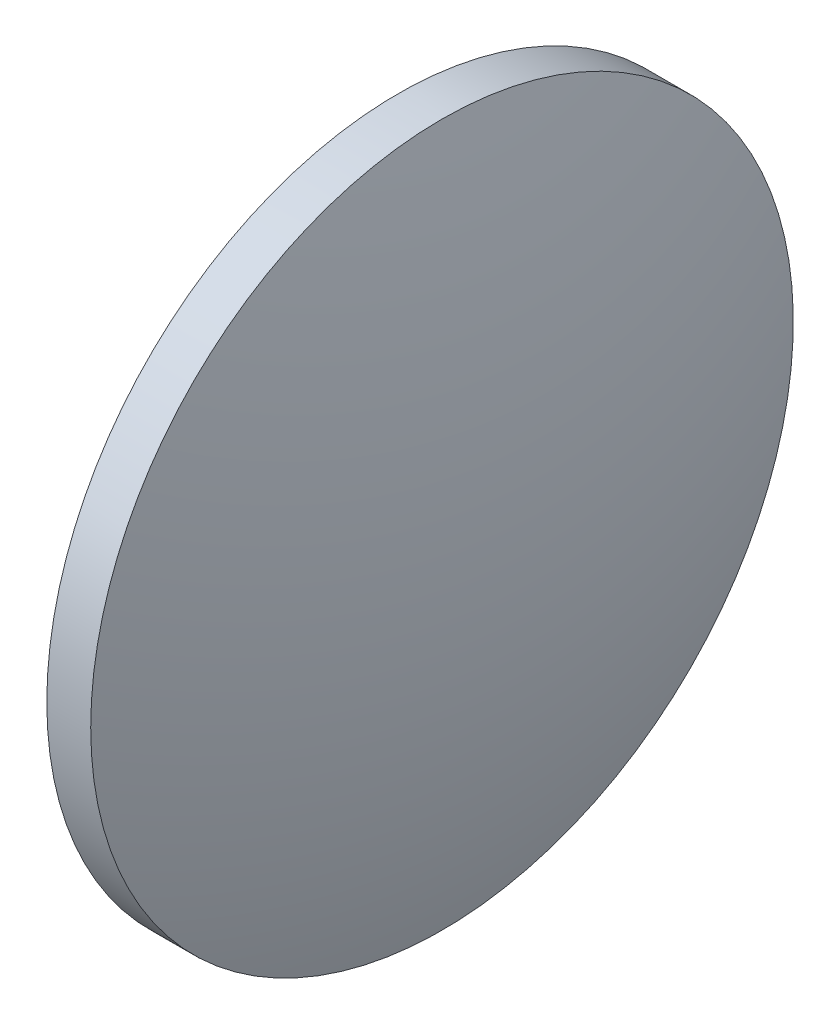
from build123d import *


with BuildPart() as part:
    # 草图1 → 旋转1 (revolve)
    with BuildSketch(Plane.XY):
        with BuildLine():
            Line((569.953013674, 216.232675746), (569.953013674, 236.232675746))
            Line((569.953013674, 236.232675746), (572.453013674, 236.232675746))
            ThreePointArc((572.453013674, 236.232675746), (574.833051602, 226.358291777), (575.633013674, 216.232675746))
            Line((575.633013674, 216.232675746), (569.953013674, 216.232675746))
        make_face()
    revolve(axis=Axis((560.446516354, 216.232675746, 0), (1, 0, 0)))


solid = part.part
